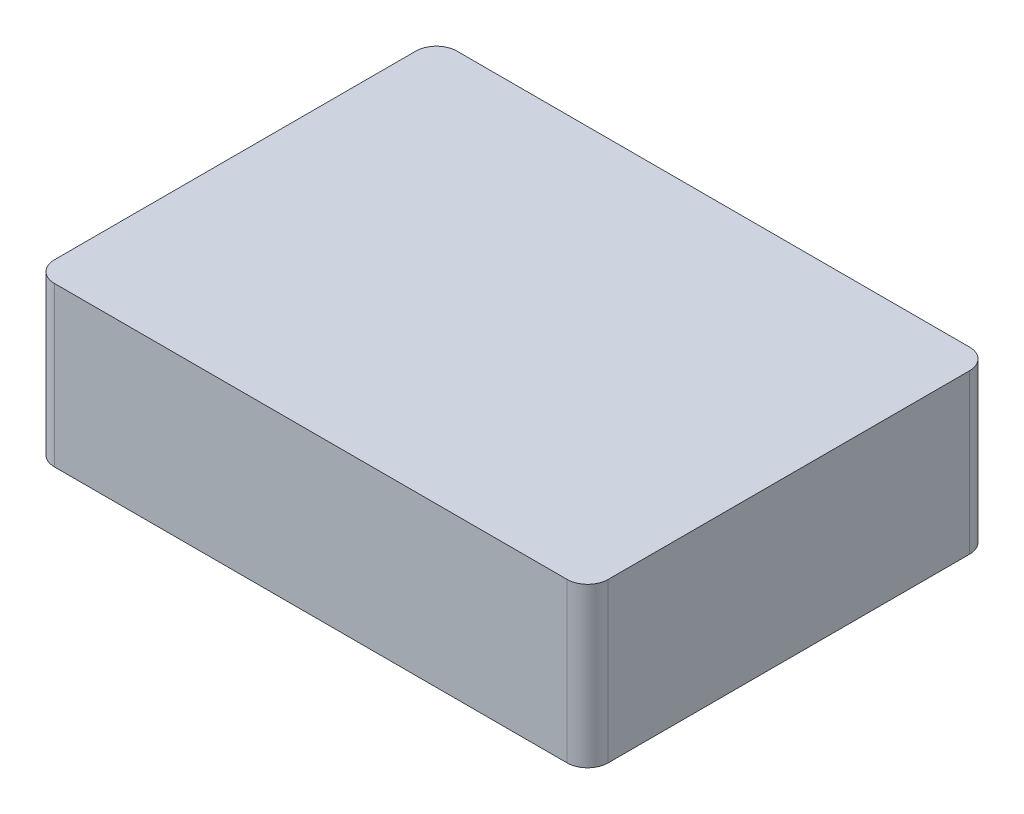
from build123d import *

# Parameters (mm, degrees)
SKETCH1_W           = 54
SKETCH1_H           = 39.25
BOSS_EXTRUDE1_DEPTH = 15.5
FILLET1_R           = 2
FILLET2_R           = 2


with BuildPart() as part:
    # Sketch1 → Boss-Extrude1 (new body)
    with BuildSketch(Plane(origin=(0, 0, 0), x_dir=(1, 0, 0), z_dir=(0, 1, 0))):
        with Locations((27, 19.625)):
            Rectangle(SKETCH1_W, SKETCH1_H)
    extrude(amount=BOSS_EXTRUDE1_DEPTH)

    # Fillet1
    fillet1_edges = [part.edges().sort_by_distance(p)[0] for p in [
        (0, 7.75, 0),
    ]]
    fillet(fillet1_edges, radius=FILLET1_R)

    # Fillet2
    fillet2_edges = [part.edges().sort_by_distance(p)[0] for p in [
        (0, 7.75, -39.25),
        (54, 7.75, -39.25),
        (54, 7.75, 0),
    ]]
    fillet(fillet2_edges, radius=FILLET2_R)


solid = part.part
